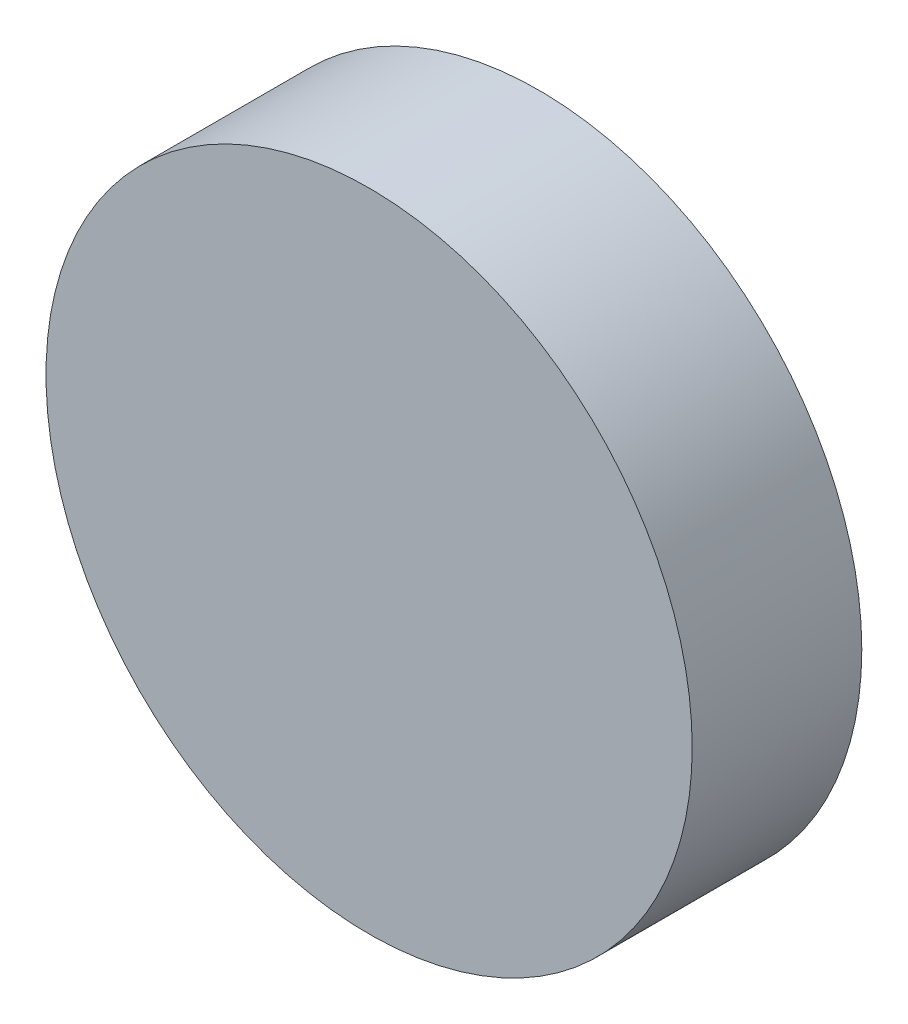
from build123d import *

# Parameters (mm, degrees)
SKETCH_1_R      = 19.05
EXTRUDE_1_DEPTH = 10


with BuildPart() as part:
    # 草图1 → 凸台-拉伸1 (new body)
    with BuildSketch(Plane.XY):
        Circle(SKETCH_1_R)
    extrude(amount=EXTRUDE_1_DEPTH)


solid = part.part
